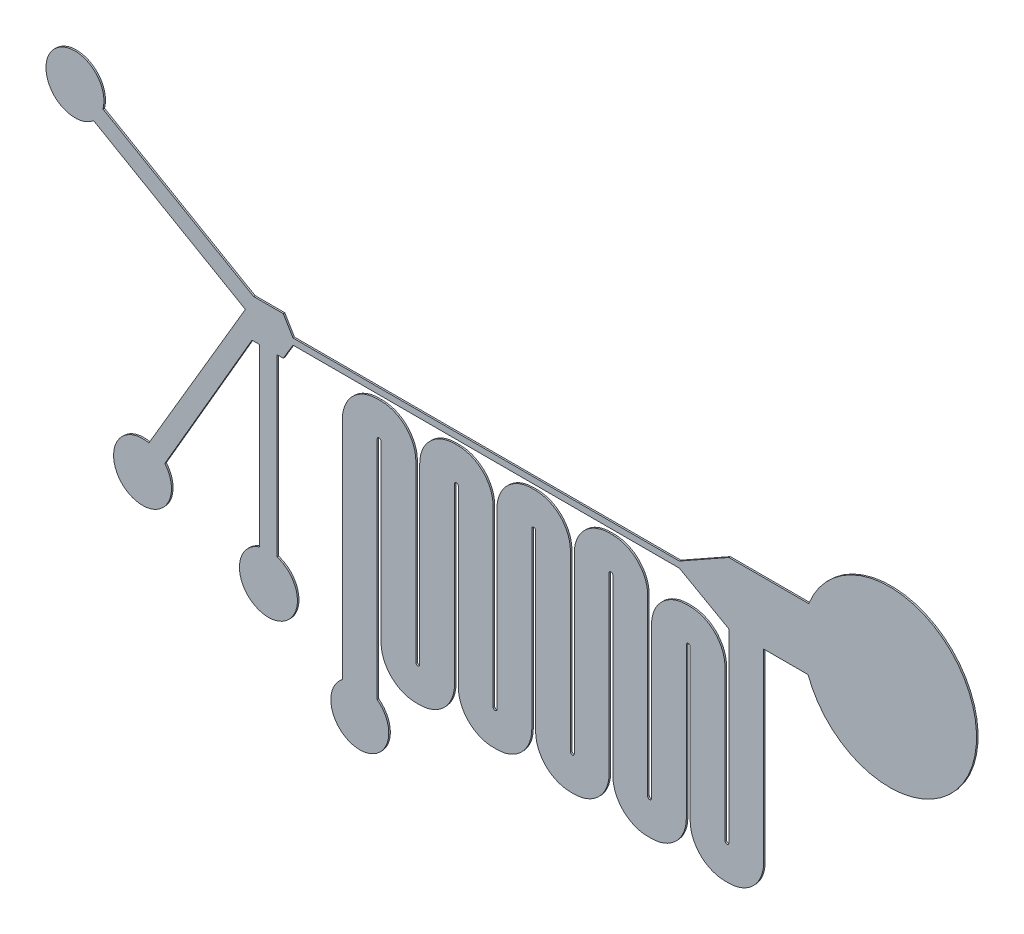
from build123d import *

# Parameters (mm, degrees)
BOSS_EXTRUDE1_DEPTH = 0.04


with BuildPart() as part:
    # Sketch1 → Boss-Extrude1 (new body)
    with BuildSketch(Plane.XY):
        with BuildLine():
            Line((-1.315144017, 0.693084069), (-1.065144017, 0.273084069))
            Line((-1.065144017, 0.273084069), (8.934855983, 0.273084069))
            Line((8.934855983, 0.273084069), (10.214855983, 0.993084069))
            Line((10.214855983, 0.993084069), (10.514506575, 0.993084069))
            Line((10.514506575, 0.993084069), (10.935378928, 0.993084069))
            Line((10.935378928, 0.993084069), (12.282731088, 0.993084069))
            ThreePointArc((12.282731088, 0.993084069), (16.626477002, 0.144456147), (12.264855983, -0.606915931))
            Line((12.264855983, -0.606915931), (11.114855983, -0.606915931))
            Line((11.114855983, -0.606915931), (11.114855983, -5.406915931))
            ThreePointArc((11.114855983, -5.406915931), (10.851252086, -6.043312034), (10.214855983, -6.306915931))
            Line((10.214855983, -6.306915931), (10.114855983, -6.306915931))
            ThreePointArc((10.114855983, -6.306915931), (9.47845988, -6.043312034), (9.214855983, -5.406915931))
            Line((9.214855983, -5.406915931), (9.214855983, -1.506915931))
            ThreePointArc((9.214855983, -1.506915931), (9.164855983, -1.456915931), (9.114855983, -1.506915931))
            Line((9.114855983, -1.506915931), (9.114855983, -5.406915931))
            ThreePointArc((9.114855983, -5.406915931), (8.851252086, -6.043312034), (8.214855983, -6.306915931))
            Line((8.214855983, -6.306915931), (8.114855983, -6.306915931))
            ThreePointArc((8.114855983, -6.306915931), (7.47845988, -6.043312034), (7.214855983, -5.406915931))
            Line((7.214855983, -5.406915931), (7.214855983, -0.904335528))
            ThreePointArc((7.214855983, -0.904335528), (7.164855983, -0.854335528), (7.114855983, -0.904335528))
            Line((7.114855983, -0.904335528), (7.114855983, -5.4112515))
            ThreePointArc((7.114855983, -5.4112515), (6.851252086, -6.047647603), (6.214855983, -6.3112515))
            Line((6.214855983, -6.3112515), (6.114855983, -6.3112515))
            ThreePointArc((6.114855983, -6.3112515), (5.47845988, -6.047647603), (5.214855983, -5.4112515))
            Line((5.214855983, -5.4112515), (5.214855983, -0.90433553))
            ThreePointArc((5.214855983, -0.90433553), (5.164851284, -0.85433083), (5.114846585, -0.90433553))
            Line((5.114846585, -0.90433553), (5.114846585, -5.4112515))
            ThreePointArc((5.114846585, -5.4112515), (4.851242688, -6.047647603), (4.214846585, -6.3112515))
            Line((4.214846585, -6.3112515), (4.114855983, -6.3112515))
            ThreePointArc((4.114855983, -6.3112515), (3.47845988, -6.047647603), (3.214855983, -5.4112515))
            Line((3.214855983, -5.4112515), (3.214855983, -0.90433553))
            ThreePointArc((3.214855983, -0.90433553), (3.164851284, -0.85433083), (3.114846585, -0.90433553))
            Line((3.114846585, -0.90433553), (3.114846585, -5.4112515))
            ThreePointArc((3.114846585, -5.4112515), (2.851242688, -6.047647603), (2.214846585, -6.3112515))
            Line((2.214846585, -6.3112515), (2.128594735, -6.3112515))
            ThreePointArc((2.128594735, -6.3112515), (1.483323335, -6.05252673), (1.214846585, -5.4112515))
            Line((1.214846585, -5.4112515), (1.214846585, -0.9))
            ThreePointArc((1.214846585, -0.9), (1.164846585, -0.85), (1.114846585, -0.9))
            Line((1.114846585, -0.9), (1.114846585, -6.592929893))
            Line((1.114846585, -6.592929893), (1.114846585, -6.742929893))
            ThreePointArc((1.114846585, -6.742929893), (0.664846585, -8.092929893), (0.214846585, -6.742929893))
            Line((0.214846585, -6.742929893), (0.214846585, -6.592929893))
            Line((0.214846585, -6.592929893), (0.214846585, -0.9))
            ThreePointArc((0.214846585, -0.9), (0.478450482, -0.263603897), (1.114846585, 0))
            Line((1.114846585, 0), (1.214846585, 0))
            ThreePointArc((1.214846585, 0), (1.852773687, -0.265138589), (2.114836142, -0.90433553))
            Line((2.114836142, -0.90433553), (2.114950011, -5.4112515))
            ThreePointArc((2.114950011, -5.4112515), (2.164898298, -5.461199786), (2.214846585, -5.4112515))
            Line((2.214846585, -5.4112515), (2.214846585, -0.90433553))
            ThreePointArc((2.214846585, -0.90433553), (2.478450482, -0.267939426), (3.114846585, -0.00433553))
            Line((3.114846585, -0.00433553), (3.214855983, -0.00433553))
            ThreePointArc((3.214855983, -0.00433553), (3.851252086, -0.267939426), (4.114855983, -0.90433553))
            Line((4.114855983, -0.90433553), (4.114855983, -5.4112515))
            ThreePointArc((4.114855983, -5.4112515), (4.164851284, -5.4612468), (4.214846585, -5.4112515))
            Line((4.214846585, -5.4112515), (4.214846585, -0.90433553))
            ThreePointArc((4.214846585, -0.90433553), (4.478450482, -0.267939426), (5.114846585, -0.00433553))
            Line((5.114846585, -0.00433553), (5.214855983, -0.00433553))
            ThreePointArc((5.214855983, -0.00433553), (5.851252086, -0.267939426), (6.114855983, -0.90433553))
            Line((6.114855983, -0.90433553), (6.114855983, -5.4112515))
            ThreePointArc((6.114855983, -5.4112515), (6.164855983, -5.4612515), (6.214855983, -5.4112515))
            Line((6.214855983, -5.4112515), (6.214855983, -0.904335528))
            ThreePointArc((6.214855983, -0.904335528), (6.47845988, -0.267939425), (7.114855983, -0.004335528))
            Line((7.114855983, -0.004335528), (7.214855983, -0.004335528))
            ThreePointArc((7.214855983, -0.004335528), (7.851252086, -0.267939425), (8.114855983, -0.904335528))
            Line((8.114855983, -0.904335528), (8.114855983, -5.406915931))
            ThreePointArc((8.114855983, -5.406915931), (8.164855983, -5.456915931), (8.214855983, -5.406915931))
            Line((8.214855983, -5.406915931), (8.214855983, -1.506915931))
            ThreePointArc((8.214855983, -1.506915931), (8.47845988, -0.870519828), (9.114855983, -0.606915931))
            Line((9.114855983, -0.606915931), (9.214855983, -0.606915931))
            ThreePointArc((9.214855983, -0.606915931), (9.851252086, -0.870519828), (10.114855983, -1.506915931))
            Line((10.114855983, -1.506915931), (10.114855983, -5.406915931))
            ThreePointArc((10.114855983, -5.406915931), (10.164855983, -5.456915931), (10.214855983, -5.406915931))
            Line((10.214855983, -5.406915931), (10.214855983, -0.606915931))
            Line((10.214855983, -0.606915931), (8.934855983, 0.113084069))
            Line((8.934855983, 0.113084069), (-1.065144017, 0.113084069))
            Line((-1.065144017, 0.113084069), (-1.315144017, -0.306915931))
            Line((-1.315144017, -0.306915931), (-1.475144017, -0.306915931))
            Line((-1.475144017, -0.306915931), (-1.475144017, -4.82261796))
            Line((-1.475144017, -4.82261796), (-1.475144017, -4.84146153))
            ThreePointArc((-1.475144017, -4.84146153), (-1.700144017, -6.306915931), (-1.925144017, -4.84146153))
            Line((-1.925144017, -4.84146153), (-1.925144017, -4.806915931))
            Line((-1.925144017, -4.806915931), (-1.925144017, -0.306915931))
            Line((-1.925144017, -0.306915931), (-2.125144017, -0.306915931))
            Line((-2.125144017, -0.306915931), (-4.345243658, -4.136400695))
            Line((-4.345243658, -4.136400695), (-4.380795568, -4.197724742))
            ThreePointArc((-4.380795568, -4.197724742), (-5.348898376, -5.316761949), (-4.795009179, -3.94465624))
            Line((-4.795009179, -3.94465624), (-2.296869562, 0.296921546))
            Line((-2.296869562, 0.296921546), (-6.192755194, 2.546212165))
            Line((-6.192755194, 2.546212165), (-6.224617122, 2.562462753))
            ThreePointArc((-6.224617122, 2.562462753), (-7.341518741, 3.537122923), (-5.982350992, 2.945434913))
            Line((-5.982350992, 2.945434913), (-5.980157496, 2.943084069))
            Line((-5.980157496, 2.943084069), (-2.421936306, 0.888744107))
            Line((-2.421936306, 0.888744107), (-2.083043179, 0.693084069))
            Line((-2.083043179, 0.693084069), (-1.625493347, 0.693084069))
            Line((-1.625493347, 0.693084069), (-1.315144017, 0.693084069))
        make_face()
    extrude(amount=BOSS_EXTRUDE1_DEPTH)


solid = part.part
